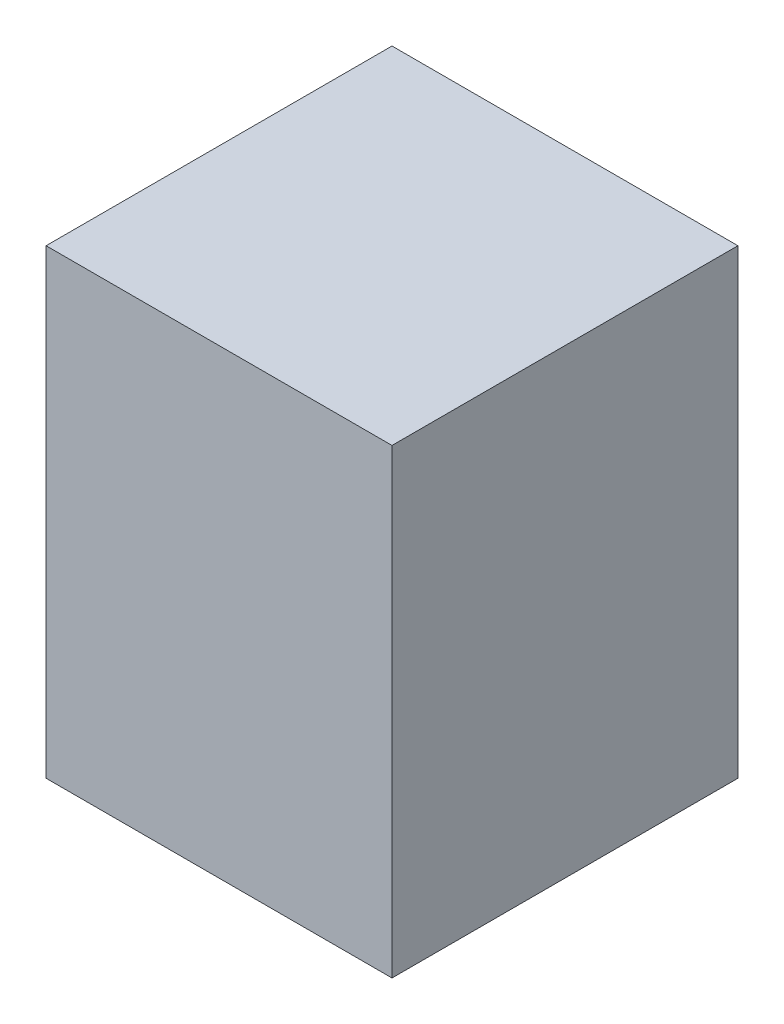
from build123d import *

# Parameters (mm, degrees)
SKETCH1_W           = 19.05
SKETCH1_H           = 19.05
BOSS_EXTRUDE1_DEPTH = 25.4


with BuildPart() as part:
    # Sketch1 → Boss-Extrude1 (new body)
    with BuildSketch(Plane(origin=(0, 0, 0), x_dir=(1, 0, 0), z_dir=(0, 1, 0))):
        with Locations((9.525, 9.525)):
            Rectangle(SKETCH1_W, SKETCH1_H)
    extrude(amount=BOSS_EXTRUDE1_DEPTH)


solid = part.part
